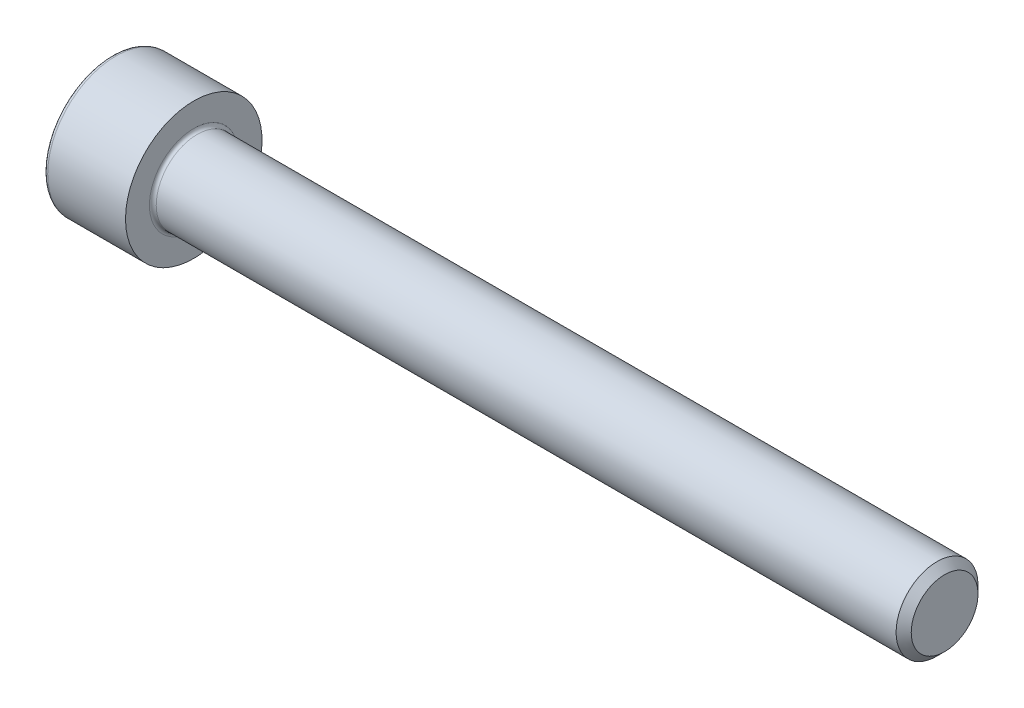
from build123d import *

# Parameters (mm, degrees)
FILLET1_R   = 0.25
FILLET2_R   = 0.3
HEX_2_DEPTH = 3


with BuildPart() as part:
    # BodySke → Base-Revolve (revolve)
    with BuildSketch(Plane.XY):
        Polygon((0, 0), (0, 5), (6, 5), (6, 3), (60.4455, 3), (61, 2.4455), (61, 0), align=None)
    revolve(axis=Axis((-31.75, 0, 0), (1, 0, 0)))

    # Fillet1
    fillet1_edges = [part.edges().sort_by_distance(p)[0] for p in [
        (6, -3, 0),
    ]]
    fillet(fillet1_edges, radius=FILLET1_R)

    # Fillet2
    fillet2_edges = [part.edges().sort_by_distance(p)[0] for p in [
        (0, -5, 0),
    ]]
    fillet(fillet2_edges, radius=FILLET2_R)

    # Sketch2 → Hex-PreBroach (revolve, cut)
    with BuildSketch(Plane.XY):
        Polygon((0, 2.542), (3, 2.542), (4.467624384, 0), (0, 0), align=None)
    revolve(axis=Axis((0, 0, 0), (1, 0, 0)), mode=Mode.SUBTRACT)

    # Sketch3 → Hex 2 (cut)
    with BuildSketch(Plane(origin=(0, 0, 0), x_dir=(0, 0.5, 0.866025404), z_dir=(-1, 0, 0))):
        Polygon((1.467624384, 2.542), (-1.467624384, 2.542), (-2.935248769, 0), (-1.467624384, -2.542), (1.467624384, -2.542), (2.935248769, 0), align=None)
    extrude(amount=-HEX_2_DEPTH, mode=Mode.SUBTRACT)


solid = part.part
